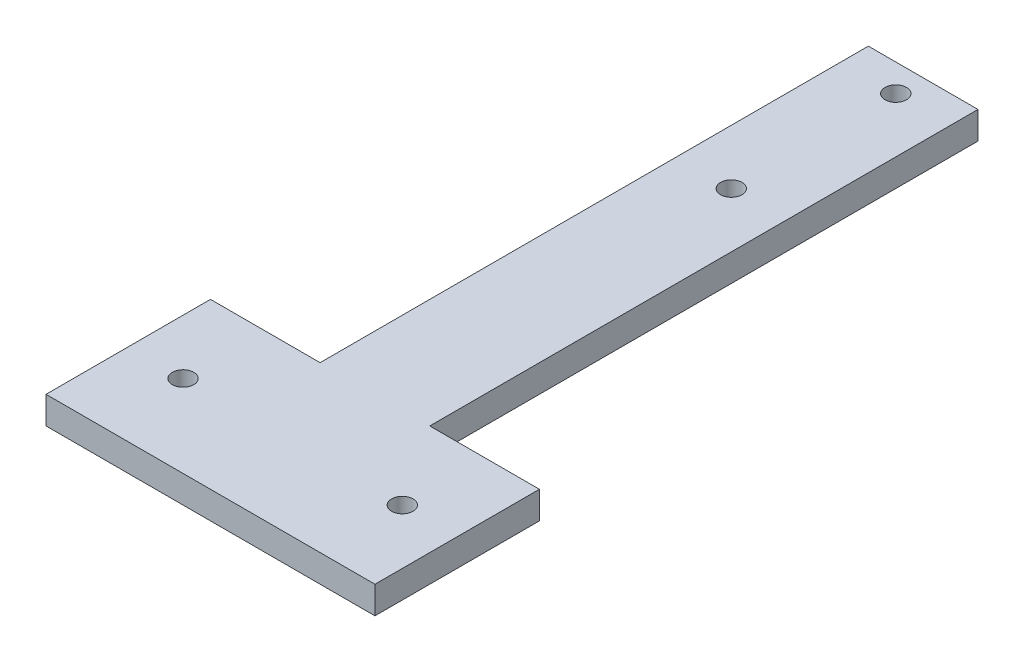
from build123d import *

# Parameters (mm, degrees)
SKETCH2_R           = 2.4892
BOSS_EXTRUDE1_DEPTH = 6.35


with BuildPart() as part:
    # Sketch2 → Boss-Extrude1 (new body)
    with BuildSketch(Plane(origin=(0, 0, 0), x_dir=(1, 0, 0), z_dir=(0, 1, 0))):
        Polygon((-12.7, 165.1), (-12.7, 38.1), (-38.1, 38.1), (-38.1, 0), (38.1, 0), (38.1, 38.1), (12.7, 38.1), (12.7, 165.1), align=None)
        with Locations((-25.4, 19.05)):
            Circle(SKETCH2_R, mode=Mode.SUBTRACT)
        with Locations((25.4, 19.05)):
            Circle(SKETCH2_R, mode=Mode.SUBTRACT)
        with Locations((0, 158.75)):
            Circle(SKETCH2_R, mode=Mode.SUBTRACT)
        with Locations((0, 120.65)):
            Circle(SKETCH2_R, mode=Mode.SUBTRACT)
    extrude(amount=BOSS_EXTRUDE1_DEPTH)


solid = part.part
